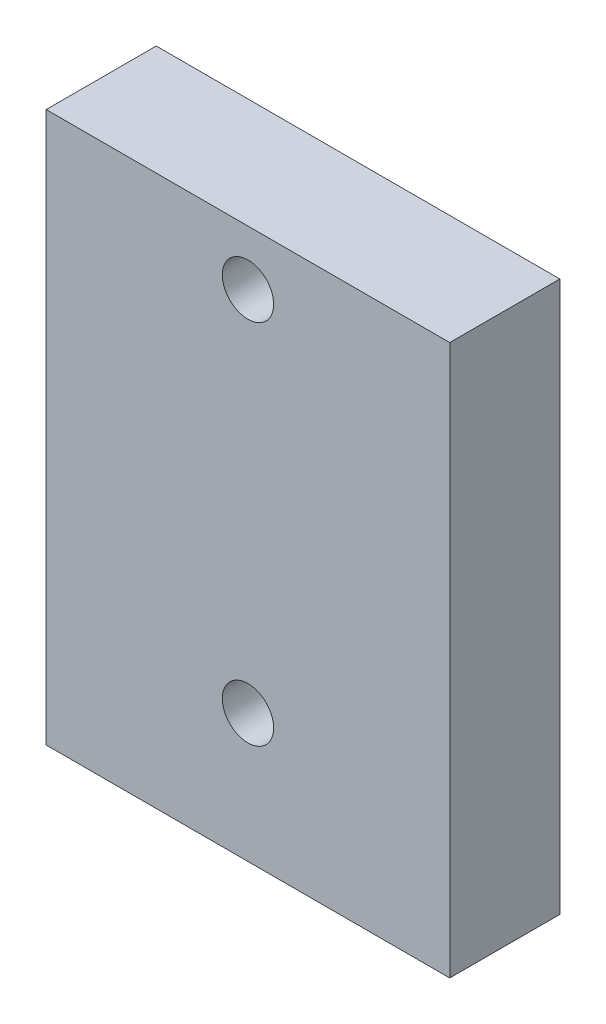
from build123d import *

# Parameters (mm, degrees)
ESQUISSE1_W        = 22
ESQUISSE1_H        = 30
ESQUISSE1_R        = 1.4
BOSS_EXTRU_1_DEPTH = 6


with BuildPart() as part:
    # Esquisse1 → Boss.-Extru.1 (new body)
    with BuildSketch(Plane.XY):
        with Locations((-4.301432764, 0.3930131)):
            Rectangle(ESQUISSE1_W, ESQUISSE1_H)
        with Locations((-4.301432764, 12.3930131)):
            Circle(ESQUISSE1_R, mode=Mode.SUBTRACT)
        with Locations((-4.301432764, -7.6069869)):
            Circle(ESQUISSE1_R, mode=Mode.SUBTRACT)
    extrude(amount=BOSS_EXTRU_1_DEPTH)


solid = part.part
